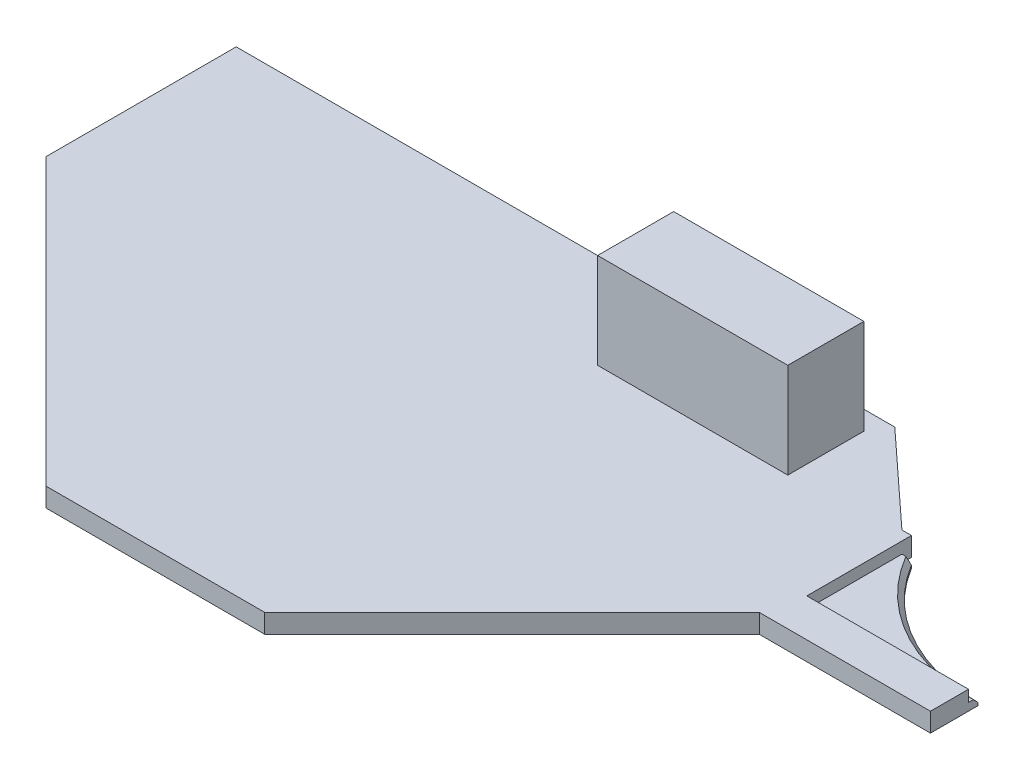
from build123d import *

# Parameters (mm, degrees)
SALIENTE_EXTRUIR2_DEPTH = 2
CROQUIS3_W              = 17
CROQUIS3_H              = 11
CORTAR_EXTRUIR1_DEPTH   = 1.2
CORTAR_EXTRUIR2_DEPTH   = 1.8
CROQUIS5_W              = 20
CROQUIS5_H              = 8
SALIENTE_EXTRUIR3_DEPTH = 10
CHAFL_N1_SIZE           = 0.5


with BuildPart() as part:
    # Croquis1 → Saliente-Extruir2 (new body)
    with BuildSketch(Plane(origin=(0, 0, 0), x_dir=(1, 0, 0), z_dir=(0, 1, 0))):
        Polygon((0, 0), (0, 20), (69.25, 20), (79, 11), (97, 11), (97, -4), (79, -4), (53, -30), (30, -30), align=None)
    extrude(amount=SALIENTE_EXTRUIR2_DEPTH)

    # Croquis3 → Cortar-Extruir1 (cut)
    with BuildSketch(Plane(origin=(0, 2, 0), x_dir=(1, 0, 0), z_dir=(0, 1, 0))):
        with Locations((88.5, 5.5)):
            Rectangle(CROQUIS3_W, CROQUIS3_H)
    extrude(amount=-CORTAR_EXTRUIR1_DEPTH, mode=Mode.SUBTRACT)

    # Croquis4 → Cortar-Extruir2 (cut, through all)
    with BuildSketch(Plane(origin=(0, 0.8, 0), x_dir=(1, 0, 0), z_dir=(0, 1, 0))):
        with BuildLine():
            Line((80, 11), (80, 10))
            Line((80, 10), (81, 10))
            ThreePointArc((81, 10), (87.821220125, 3.404391333), (97, 1))
            Line((97, 1), (97, 11))
            Line((97, 11), (80, 11))
        make_face()
    extrude(amount=-CORTAR_EXTRUIR2_DEPTH, mode=Mode.SUBTRACT)

    # Croquis5 → Saliente-Extruir3 (add)
    with BuildSketch(Plane(origin=(0, 2, 0), x_dir=(1, 0, 0), z_dir=(0, 1, 0))):
        with Locations((58, 14)):
            Rectangle(CROQUIS5_W, CROQUIS5_H)
    extrude(amount=SALIENTE_EXTRUIR3_DEPTH)

    # Chaflán1
    chafl_n1_edges = [part.edges().sort_by_distance(p)[0] for p in [
        (87.821220125, 0.8, -3.404391333),
    ]]
    chamfer(chafl_n1_edges, length=CHAFL_N1_SIZE)


solid = part.part
